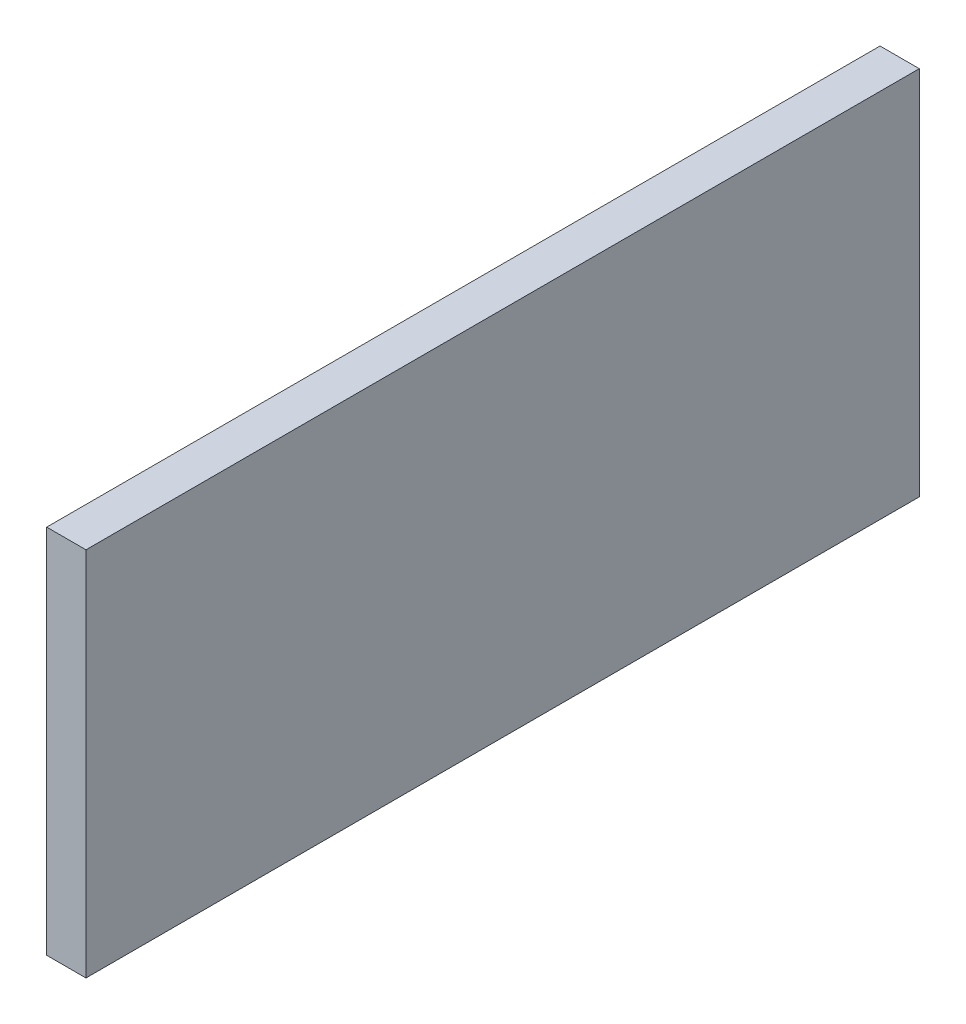
from build123d import *

# Parameters (mm, degrees)
SKETCH1_W           = 382
SKETCH1_H           = 170
BOSS_EXTRUDE1_DEPTH = 18


with BuildPart() as part:
    # Sketch1 → Boss-Extrude1 (new body)
    with BuildSketch(Plane(origin=(0, 0, 0), x_dir=(0, 0, -1), z_dir=(1, 0, 0))):
        with Locations((196.489195297, 64.807603013)):
            Rectangle(SKETCH1_W, SKETCH1_H)
    extrude(amount=BOSS_EXTRUDE1_DEPTH)


solid = part.part
